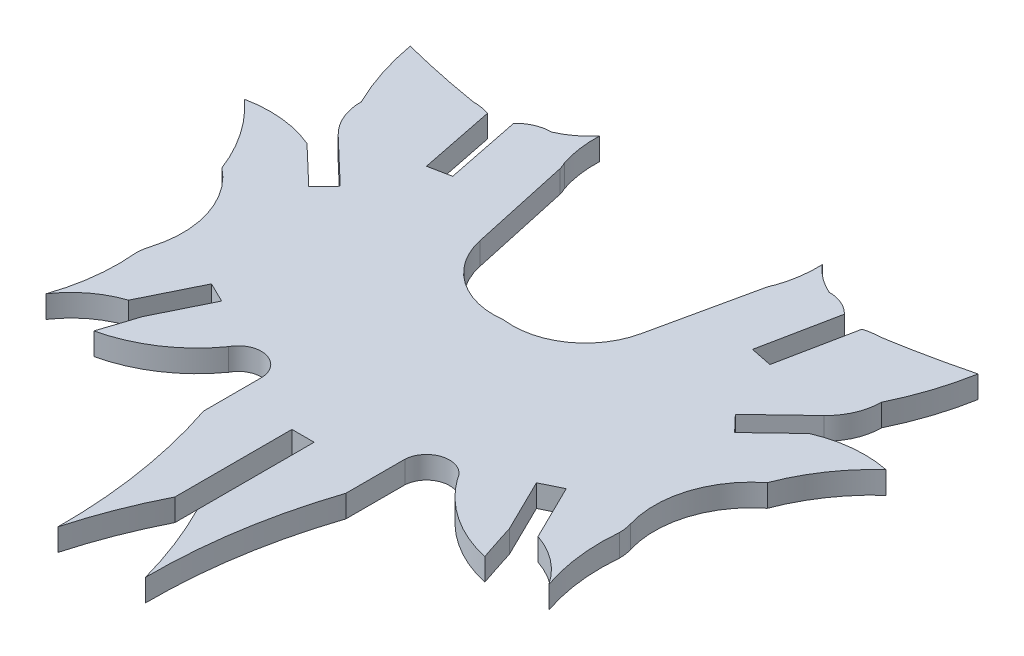
from build123d import *

# Parameters (mm, degrees)
BOSS_EXTRUDE1_DEPTH = 1.524


with BuildPart() as part:
    # Sketch1 → Boss-Extrude1 (new body)
    with BuildSketch(Plane(origin=(0, 0, 0), x_dir=(1, 0, 0), z_dir=(0, 1, 0))):
        with BuildLine():
            Line((5.520593562, 10.562997869), (7.050708645, 17.571208446))
            ThreePointArc((7.050708645, 17.571208446), (7.131145016, 17.829150642), (7.238606677, 18.077054207))
            ThreePointArc((7.238606677, 18.077054207), (7.564510049, 19.45989002), (7.637457251, 20.878736946))
            ThreePointArc((7.637457251, 20.878736946), (8.492098945, 20.073618252), (9.504942938, 19.47966911))
            ThreePointArc((9.504942938, 19.47966911), (10.499295157, 19.276273595), (11.333912028, 18.698761041))
            Line((11.333912028, 18.698761041), (10.277523058, 13.457219083))
            Line((10.277523058, 13.457219083), (11.773700319, 13.155201971))
            Line((11.773700319, 13.155201971), (12.828772876, 18.399768932))
            ThreePointArc((12.828772876, 18.399768932), (13.409499296, 18.538098505), (14.004660893, 18.584584187))
            ThreePointArc((14.004660893, 18.584584187), (16.746835107, 19.097796263), (19.463914435, 19.730556864))
            ThreePointArc((19.463914435, 19.730556864), (18.823035781, 17.184750652), (17.837865312, 14.751379768))
            ThreePointArc((17.837865312, 14.751379768), (17.528924841, 13.243726046), (16.651902084, 11.979093671))
            Line((16.651902084, 11.979093671), (13.544076564, 9.012401066))
            Line((13.544076564, 9.012401066), (14.59914963, 7.908648182))
            Line((14.59914963, 7.908648182), (17.221929817, 10.411217166))
            ThreePointArc((17.221929817, 10.411217166), (19.571015538, 11.015907736), (21.993615768, 10.893995741))
            ThreePointArc((21.993615768, 10.893995741), (20.058776223, 8.670441452), (18.698609679, 6.055533286))
            ThreePointArc((18.698609679, 6.055533286), (16.478620051, 2.831263642), (16.457225541, -1.083300314))
            ThreePointArc((16.457225541, -1.083300314), (16.55614989, -1.524335384), (16.589363804, -1.975106719))
            ThreePointArc((16.589363804, -1.975106719), (16.624442109, -4.753141238), (17.243254302, -7.461605332))
            ThreePointArc((17.243254302, -7.461605332), (15.84253831, -5.968117791), (14.035036599, -5.006115769))
            Line((14.035036599, -5.006115769), (12.161156101, -1.197565278))
            Line((12.161156101, -1.197565278), (10.792144449, -1.871143044))
            Line((10.792144449, -1.871143044), (12.582390495, -5.515217687))
            ThreePointArc((12.582390495, -5.515217687), (12.984657899, -6.771031753), (13.401445653, -8.022101696))
            ThreePointArc((13.401445653, -8.022101696), (10.284977839, -6.689966631), (7.846889336, -4.335676947))
            ThreePointArc((7.846889336, -4.335676947), (6.119650246, -3.528046665), (4.880261331, -4.977024464))
            Line((4.880261331, -4.977024464), (4.878620901, -9.02232865))
            ThreePointArc((4.878620901, -9.02232865), (3.451641907, -14.873313942), (2.99866015, -20.878736946))
            ThreePointArc((2.99866015, -20.878736946), (2.023183201, -17.933730156), (0.761997186, -15.099293685))
            Line((0.761997186, -15.099293685), (0.761997186, -7.081931903))
            Line((0.761997186, -7.081931903), (-0.761997186, -7.081931903))
            Line((-0.761997186, -7.081931903), (-0.761997186, -15.100287099))
            ThreePointArc((-0.761997186, -15.100287099), (-2.023137189, -17.934235169), (-2.99866015, -20.878736946))
            ThreePointArc((-2.99866015, -20.878736946), (-3.451641907, -14.873313942), (-4.878620901, -9.02232865))
            Line((-4.878620901, -9.02232865), (-4.880261331, -4.977024464))
            ThreePointArc((-4.880261331, -4.977024464), (-6.119650246, -3.528046665), (-7.846889336, -4.335676947))
            ThreePointArc((-7.846889336, -4.335676947), (-10.284977839, -6.689966631), (-13.401445653, -8.022101696))
            ThreePointArc((-13.401445653, -8.022101696), (-12.984657899, -6.771031753), (-12.582390495, -5.515217687))
            Line((-12.582390495, -5.515217687), (-10.792144449, -1.871143044))
            Line((-10.792144449, -1.871143044), (-12.161156101, -1.197565278))
            Line((-12.161156101, -1.197565278), (-14.035036599, -5.006115769))
            ThreePointArc((-14.035036599, -5.006115769), (-15.84253831, -5.968117791), (-17.243254302, -7.461605332))
            ThreePointArc((-17.243254302, -7.461605332), (-16.624442109, -4.753141238), (-16.589363804, -1.975106719))
            ThreePointArc((-16.589363804, -1.975106719), (-16.55614989, -1.524335384), (-16.457225541, -1.083300314))
            ThreePointArc((-16.457225541, -1.083300314), (-16.478620051, 2.831263642), (-18.698609679, 6.055533286))
            ThreePointArc((-18.698609679, 6.055533286), (-20.058776223, 8.670441452), (-21.993615768, 10.893995741))
            ThreePointArc((-21.993615768, 10.893995741), (-19.571015538, 11.015907736), (-17.221929817, 10.411217166))
            Line((-17.221929817, 10.411217166), (-14.59914963, 7.908648182))
            Line((-14.59914963, 7.908648182), (-13.544076564, 9.012401066))
            Line((-13.544076564, 9.012401066), (-16.651902084, 11.979093671))
            ThreePointArc((-16.651902084, 11.979093671), (-17.528924841, 13.243726046), (-17.837865312, 14.751379768))
            ThreePointArc((-17.837865312, 14.751379768), (-18.823035781, 17.184750652), (-19.463914435, 19.730556864))
            ThreePointArc((-19.463914435, 19.730556864), (-16.746835107, 19.097796263), (-14.004660893, 18.584584187))
            ThreePointArc((-14.004660893, 18.584584187), (-13.409499296, 18.538098505), (-12.828772876, 18.399768932))
            Line((-12.828772876, 18.399768932), (-11.773700319, 13.155201971))
            Line((-11.773700319, 13.155201971), (-10.277523058, 13.457219083))
            Line((-10.277523058, 13.457219083), (-11.333912028, 18.698761041))
            ThreePointArc((-11.333912028, 18.698761041), (-10.499295157, 19.276273595), (-9.504942938, 19.47966911))
            ThreePointArc((-9.504942938, 19.47966911), (-8.492098945, 20.073618252), (-7.637457251, 20.878736946))
            ThreePointArc((-7.637457251, 20.878736946), (-7.564510049, 19.45989002), (-7.238606677, 18.077054207))
            ThreePointArc((-7.238606677, 18.077054207), (-7.131145016, 17.829150642), (-7.050708645, 17.571208446))
            Line((-7.050708645, 17.571208446), (-5.520593562, 10.562997869))
            ThreePointArc((-5.520593562, 10.562997869), (-3.516439493, 7.545594261), (0.000595641, 6.678517605))
            ThreePointArc((0.000595641, 6.678517605), (3.516886937, 7.546036839), (5.520593562, 10.562997869))
        make_face()
    extrude(amount=BOSS_EXTRUDE1_DEPTH)


solid = part.part
